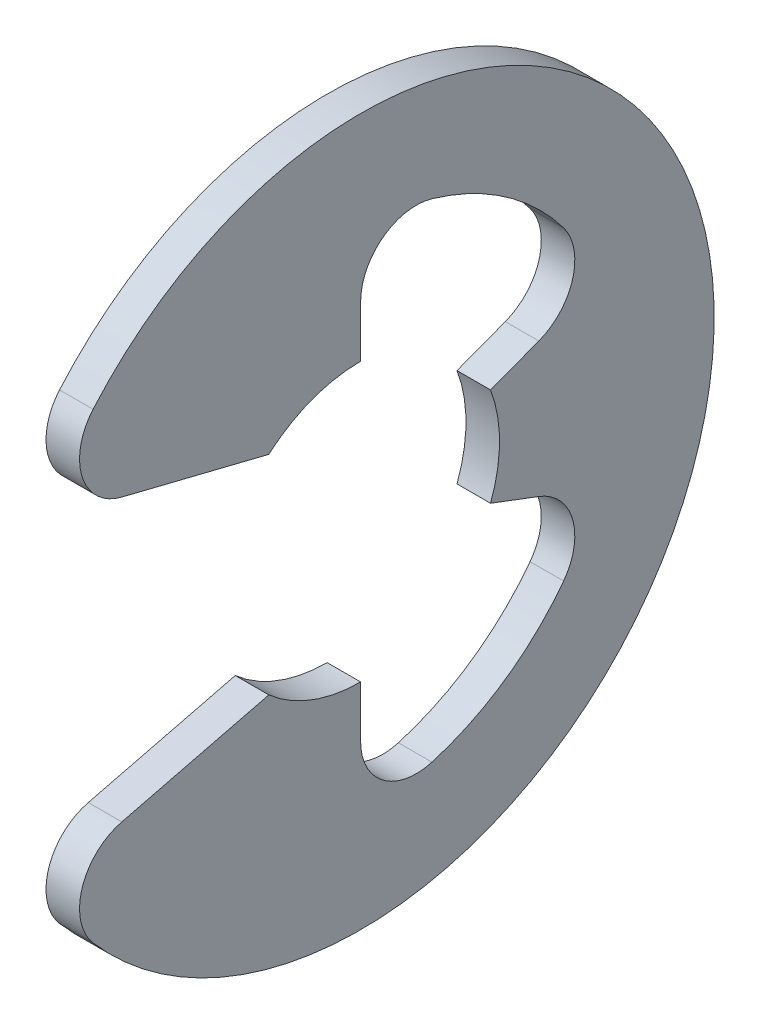
from build123d import *

# Parameters (mm, degrees)
EXTRUDE1_DEPTH = 0.3175
FILLET1_R      = 1.0541


with BuildPart() as part:
    # Sketch1 → Extrude1 (new body, symmetric)
    with BuildSketch(Plane(origin=(0, 0, 0), x_dir=(0, 0, -1), z_dir=(1, 0, 0))):
        with BuildLine():
            Line((-5.971542337, -3.022514273), (-1.738853905, -1.971675))
            ThreePointArc((-1.738853905, -1.971675), (-0.929456509, -2.459110776), (0, -2.6289))
            Line((0, -2.6289), (0, -4.811251613))
            ThreePointArc((0, -4.811251613), (2.735327948, -3.958045364), (4.500513784, -1.701034321))
            Line((4.500513784, -1.701034321), (2.459110776, -0.929456509))
            ThreePointArc((2.459110776, -0.929456509), (2.6289, 0), (2.459110776, 0.929456509))
            Line((2.459110776, 0.929456509), (4.500513784, 1.701034321))
            ThreePointArc((4.500513784, 1.701034321), (2.735327948, 3.958045364), (0, 4.811251613))
            Line((0, 4.811251613), (0, 2.6289))
            ThreePointArc((0, 2.6289), (-0.929456509, 2.459110776), (-1.738853905, 1.971675))
            Line((-1.738853905, 1.971675), (-5.971542337, 3.022514273))
            ThreePointArc((-5.971542337, 3.022514273), (6.6929, 0), (-5.971542337, -3.022514273))
        make_face()
    extrude(amount=EXTRUDE1_DEPTH, both=True)

    # Fillet1
    fillet1_edges = [part.edges().sort_by_distance(p)[0] for p in [
        (0, -3.022514273, 5.971542337),
        (0, -4.811251613, 0),
        (0, -1.701034321, -4.500513784),
        (0, 1.701034321, -4.500513784),
        (0, 4.811251613, 0),
        (0, 3.022514273, 5.971542337),
    ]]
    fillet(fillet1_edges, radius=FILLET1_R)


solid = part.part
